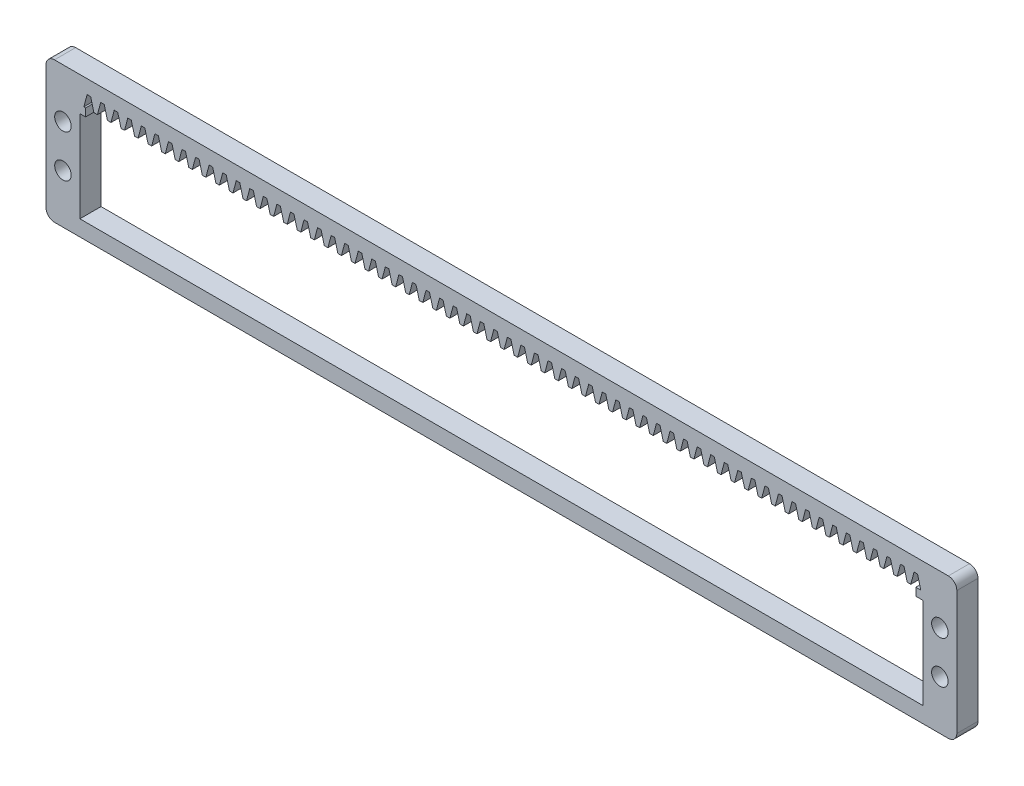
from build123d import *

# Parameters (mm, degrees)
BOSS_EXTRUDE1_DEPTH = 5
SKETCH2_W           = 199
SKETCH2_H           = 21.5
CUT_EXTRUDE1_DEPTH  = 6
SKETCH3_W           = 195.97
SKETCH3_H           = 1.85
CUT_EXTRUDE2_DEPTH  = 6
CUT_EXTRUDE4_DEPTH  = 6
LPATTERN1_COUNT     = 62
LPATTERN1_PITCH     = 3.2
SKETCH5_R           = 1.95
CUT_EXTRUDE5_DEPTH  = 10


with BuildPart() as part:
    # Sketch1 → Boss-Extrude1 (new body)
    with BuildSketch(Plane.XY):
        with BuildLine():
            Line((2, 0), (213, 0))
            ThreePointArc((213, 0), (214.414213562, -0.585786438), (215, -2))
            Line((215, -2), (215, -31.22))
            ThreePointArc((215, -31.22), (214.414213562, -32.634213562), (213, -33.22))
            Line((213, -33.22), (2, -33.22))
            ThreePointArc((2, -33.22), (0.585786438, -32.634213562), (0, -31.22))
            Line((0, -31.22), (0, -2))
            ThreePointArc((0, -2), (0.585786438, -0.585786438), (2, 0))
        make_face()
    extrude(amount=BOSS_EXTRUDE1_DEPTH)

    # Sketch2 → Cut-Extrude1 (cut, through all)
    with BuildSketch(Plane.XY.offset(5)):
        with Locations((107.5, -18.75)):
            Rectangle(SKETCH2_W, SKETCH2_H)
    extrude(amount=-CUT_EXTRUDE1_DEPTH, mode=Mode.SUBTRACT)

    # Sketch3 → Cut-Extrude2 (cut, through all)
    with BuildSketch(Plane.XY.offset(5)):
        with Locations((107.335, -7.075)):
            Rectangle(SKETCH3_W, SKETCH3_H)
    extrude(amount=-CUT_EXTRUDE2_DEPTH, mode=Mode.SUBTRACT)

    # Sketch4 → Cut-Extrude4 (cut, through all)
    with BuildSketch(Plane.XY.offset(5)):
        Polygon((205.735, -3.249176841), (206.5, -6.15), (204.14, -6.15), (204.905, -3.249176841), align=None)
    cut_extrude4 = extrude(amount=-CUT_EXTRUDE4_DEPTH, mode=Mode.SUBTRACT)

    # LPattern1: Cut-Extrude4 ×62
    with Locations(*[(-i * LPATTERN1_PITCH, 0, 0) for i in range(1, LPATTERN1_COUNT)]):
        add(cut_extrude4, mode=Mode.SUBTRACT)

    # Sketch5 → Cut-Extrude5 (cut)
    with BuildSketch(Plane.XY.offset(5)):
        with Locations((4, -11.61)):
            Circle(SKETCH5_R)
        with Locations((4, -21.61)):
            Circle(SKETCH5_R)
        with Locations((211, -11.61)):
            Circle(SKETCH5_R)
        with Locations((211, -21.61)):
            Circle(SKETCH5_R)
    extrude(amount=-CUT_EXTRUDE5_DEPTH, mode=Mode.SUBTRACT)


solid = part.part
